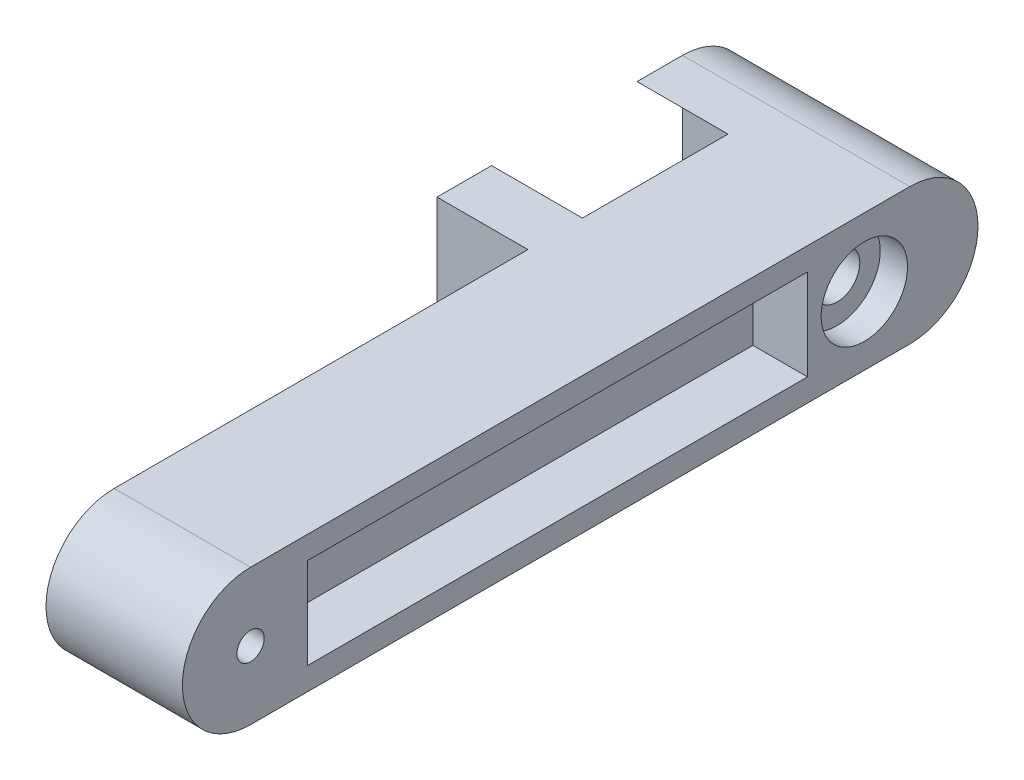
from build123d import *

# Parameters (mm, degrees)
BOSS_EXTRUDE1_DEPTH = 30
SKETCH2_R           = 3
CUT_EXTRUDE1_DEPTH  = 30
SKETCH3_R           = 9.5
CUT_EXTRUDE2_DEPTH  = 6
SKETCH4_R           = 9.5
CUT_EXTRUDE3_DEPTH  = 6
CUT_EXTRUDE4_REACH  = 26
SKETCH5_R           = 5
SKETCH6_W           = 110
SKETCH6_H           = 20
CUT_EXTRUDE5_DEPTH  = 12
SKETCH7_W           = 110
SKETCH7_H           = 20
CUT_EXTRUDE6_DEPTH  = 12
SKETCH8_W           = 12
SKETCH8_H           = 30
BOSS_EXTRUDE2_DEPTH = 32
CUT_EXTRUDE7_DEPTH  = 35
BOSS_EXTRUDE3_DEPTH = 50
SKETCH11_R          = 1.5
CUT_EXTRUDE8_DEPTH  = 10
SKETCH13_R          = 1.5
CUT_EXTRUDE9_DEPTH  = 10
SKETCH12_R          = 1.5
CUT_EXTRUDE10_DEPTH = 10


with BuildPart() as part:
    # Sketch1 → Boss-Extrude1 (new body)
    with BuildSketch(Plane(origin=(0, 0, 0), x_dir=(0, 0, -1), z_dir=(1, 0, 0))):
        with BuildLine():
            Line((0, 30), (135, 30))
            ThreePointArc((135, 30), (150, 15), (135, 0))
            Line((135, 0), (0, 0))
            ThreePointArc((0, 0), (-15, 15), (0, 30))
        make_face()
    extrude(amount=BOSS_EXTRUDE1_DEPTH)

    # Sketch2 → Cut-Extrude1 (cut)
    with BuildSketch(Plane(origin=(30, 0, 0), x_dir=(0, 0, -1), z_dir=(1, 0, 0))):
        with Locations((0, 15)):
            Circle(SKETCH2_R)
    extrude(amount=-CUT_EXTRUDE1_DEPTH, mode=Mode.SUBTRACT)

    # Sketch3 → Cut-Extrude2 (cut)
    with BuildSketch(Plane(origin=(30, 0, 0), x_dir=(0, 0, -1), z_dir=(1, 0, 0))):
        with Locations((135, 15)):
            Circle(SKETCH3_R)
    extrude(amount=-CUT_EXTRUDE2_DEPTH, mode=Mode.SUBTRACT)

    # Sketch4 → Cut-Extrude3 (cut)
    with BuildSketch(Plane.ZY):
        with Locations((-135, 15)):
            Circle(SKETCH4_R)
    extrude(amount=-CUT_EXTRUDE3_DEPTH, mode=Mode.SUBTRACT)

    # Sketch5 → Cut-Extrude4 (cut, up to next)
    with BuildSketch(Plane.ZY.offset(-6), mode=Mode.PRIVATE) as cut_extrude4_sk1:
        with Locations((-135, 15)):
            Circle(SKETCH5_R)
    cut_extrude4_tool1 = extrude(cut_extrude4_sk1.sketch, amount=-CUT_EXTRUDE4_REACH, mode=Mode.PRIVATE) & part.part
    add(cut_extrude4_tool1.solids().sort_by_distance((6, 15, -135))[0], mode=Mode.SUBTRACT)

    # Sketch6 → Cut-Extrude5 (cut)
    with BuildSketch(Plane(origin=(30, 0, 0), x_dir=(0, 0, -1), z_dir=(1, 0, 0))):
        with Locations((67.5, 15)):
            Rectangle(SKETCH6_W, SKETCH6_H)
    extrude(amount=-CUT_EXTRUDE5_DEPTH, mode=Mode.SUBTRACT)

    # Sketch7 → Cut-Extrude6 (cut)
    with BuildSketch(Plane.ZY):
        with Locations((-67.5, 15)):
            Rectangle(SKETCH7_W, SKETCH7_H)
    extrude(amount=-CUT_EXTRUDE6_DEPTH, mode=Mode.SUBTRACT)

    # Sketch8 → Boss-Extrude2 (add)
    with BuildSketch(Plane.ZY.offset(-12)):
        with Locations((-97, 15)):
            Rectangle(SKETCH8_W, SKETCH8_H)
        with Locations((-151, 15)):
            Rectangle(SKETCH8_W, SKETCH8_H)
    extrude(amount=BOSS_EXTRUDE2_DEPTH)

    # Sketch9 → Cut-Extrude7 (cut)
    with BuildSketch(Plane(origin=(12, 0, 0), x_dir=(0, 0, -1), z_dir=(1, 0, 0))):
        with BuildLine():
            Line((145, 30), (145, 26.180339887))
            ThreePointArc((145, 26.180339887), (150, 15), (145, 3.819660113))
            Line((145, 3.819660113), (145, 0))
            Line((145, 0), (157, 0))
            Line((157, 0), (157, 30))
            Line((157, 30), (145, 30))
        make_face()
    extrude(amount=-CUT_EXTRUDE7_DEPTH, mode=Mode.SUBTRACT)

    # Sketch10 → Boss-Extrude3 (add)
    with BuildSketch(Plane(origin=(30, 0, 0), x_dir=(0, 0, -1), z_dir=(1, 0, 0))):
        with BuildLine():
            Line((135, 30), (145, 30))
            ThreePointArc((145, 30), (160, 15), (145, 0))
            Line((145, 0), (135, 0))
            ThreePointArc((135, 0), (150, 15), (135, 30))
        make_face()
    extrude(amount=-BOSS_EXTRUDE3_DEPTH)

    # Sketch11 → Cut-Extrude8 (cut)
    with BuildSketch(Plane.ZY.offset(20)):
        with Locations((-149.85, 10.350189987)):
            Circle(SKETCH11_R)
    extrude(amount=-CUT_EXTRUDE8_DEPTH, mode=Mode.SUBTRACT)

    # Sketch13 → Cut-Extrude9 (cut)
    with BuildSketch(Plane.ZY.offset(20)):
        with Locations((-149.85, 20.350189987)):
            Circle(SKETCH13_R)
        with Locations((-99.35, 20.350189987)):
            Circle(SKETCH13_R)
    extrude(amount=-CUT_EXTRUDE9_DEPTH, mode=Mode.SUBTRACT)

    # Sketch12 → Cut-Extrude10 (cut)
    with BuildSketch(Plane.ZY.offset(20)):
        with Locations((-99.35, 10.350189987)):
            Circle(SKETCH12_R)
    extrude(amount=-CUT_EXTRUDE10_DEPTH, mode=Mode.SUBTRACT)


solid = part.part
